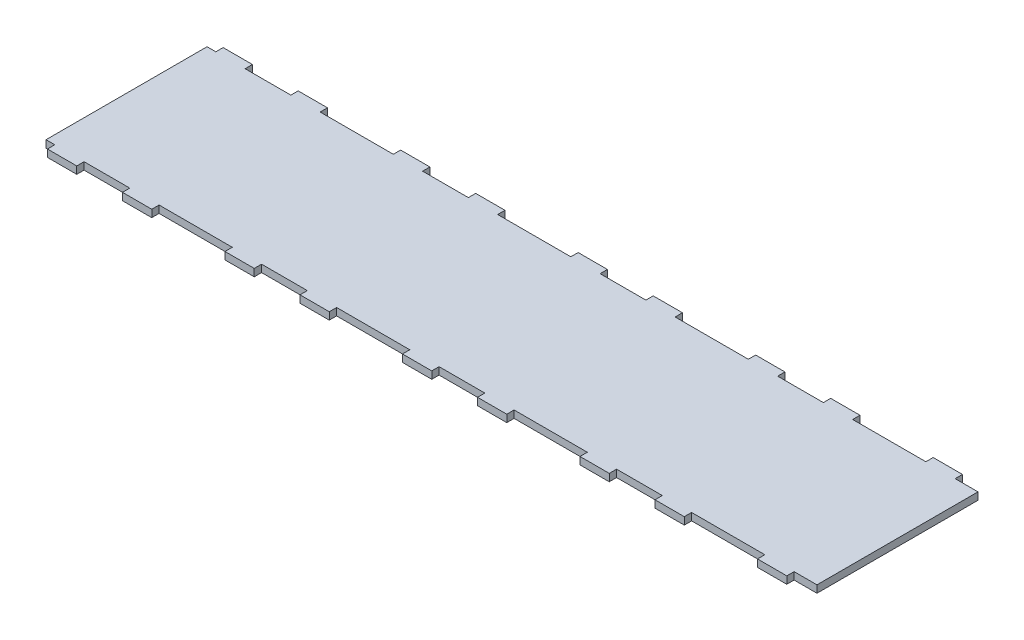
from build123d import *

# Parameters (mm, degrees)
SKETCH1_W                 = 721.63658441
SKETCH1_H                 = 152.4
BOSS_EXTRUDE1_DEPTH       = 6.35
SKETCH2_W                 = 39.679316882
SKETCH2_H                 = 6.35
SKETCH2_W_2               = 31.750000127
CUT_EXTRUDE1_DEPTH        = 7.35
LPATTERN1_COUNT           = 3
LPATTERN1_PITCH           = 153.979316882
LPATTERN1_COL_COUNT       = 3
LPATTERN1_COL_PITCH       = 153.979316882
MIRROR1_COPY_1_SKETCH_W   = 39.679316882
MIRROR1_COPY_1_SKETCH_H   = 6.35
MIRROR1_COPY_1_SKETCH_W_2 = 31.750000127
MIRROR1_COPY_1_DEPTH      = 7.35
MIRROR1_COPY_2_SKETCH_W   = 39.679316882
MIRROR1_COPY_2_SKETCH_H   = 6.35
MIRROR1_COPY_2_SKETCH_W_2 = 31.750000127
MIRROR1_COPY_2_DEPTH      = 7.35
MIRROR1_COPY_3_SKETCH_W   = 39.679316882
MIRROR1_COPY_3_SKETCH_H   = 6.35
MIRROR1_COPY_3_SKETCH_W_2 = 31.750000127
MIRROR1_COPY_3_DEPTH      = 7.35
MIRROR1_COPY_4_SKETCH_W   = 39.679316882
MIRROR1_COPY_4_SKETCH_H   = 6.35
MIRROR1_COPY_4_SKETCH_W_2 = 31.750000127
MIRROR1_COPY_4_DEPTH      = 7.35
CUT_EXTRUDE2_DEPTH        = 7.35


with BuildPart() as part:
    # Sketch1 → Boss-Extrude1 (new body)
    with BuildSketch(Plane(origin=(0, 0, 0), x_dir=(1, 0, 0), z_dir=(0, 1, 0))):
        Rectangle(SKETCH1_W, SKETCH1_H)
    extrude(amount=BOSS_EXTRUDE1_DEPTH)

    # Sketch2 → Cut-Extrude1 (cut, through all)
    with BuildSketch(Plane(origin=(0, 6.35, 0), x_dir=(1, 0, 0), z_dir=(0, 1, 0))):
        with Locations((0, -73.025)):
            Rectangle(SKETCH2_W, SKETCH2_H)
        with Locations((-61.114658505, -73.025)):
            Rectangle(SKETCH2_W_2, SKETCH2_H)
        with Locations((61.114658505, -73.025)):
            Rectangle(SKETCH2_W_2, SKETCH2_H)
    cut_extrude1 = extrude(amount=-CUT_EXTRUDE1_DEPTH, mode=Mode.SUBTRACT)

    # LPattern1: Cut-Extrude1 ×3
    with Locations(*[(i * LPATTERN1_PITCH, 0, 0) for i in range(1, LPATTERN1_COUNT)]):
        add(cut_extrude1, mode=Mode.SUBTRACT)

    # LPattern1 col: Cut-Extrude1 ×3
    with Locations(*[(-i * LPATTERN1_COL_PITCH, 0, 0) for i in range(1, LPATTERN1_COL_COUNT)]):
        add(cut_extrude1, mode=Mode.SUBTRACT)

    # Mirror1: Cut-Extrude1 across plane
    add(cut_extrude1.mirror(Plane.XY), mode=Mode.SUBTRACT)

    # Mirror1 copy 1 sketch → Mirror1 copy 1 (cut, through all)
    with BuildSketch(Plane(origin=(153.979316882, 6.35, 0), x_dir=(1, 0, 0), z_dir=(0, 1, 0))):
        with Locations((0, 73.025)):
            Rectangle(MIRROR1_COPY_1_SKETCH_W, MIRROR1_COPY_1_SKETCH_H)
        with Locations((-61.114658505, 73.025)):
            Rectangle(MIRROR1_COPY_1_SKETCH_W_2, MIRROR1_COPY_1_SKETCH_H)
        with Locations((61.114658505, 73.025)):
            Rectangle(MIRROR1_COPY_1_SKETCH_W_2, MIRROR1_COPY_1_SKETCH_H)
    extrude(amount=-MIRROR1_COPY_1_DEPTH, mode=Mode.SUBTRACT)

    # Mirror1 copy 2 sketch → Mirror1 copy 2 (cut, through all)
    with BuildSketch(Plane(origin=(307.958633764, 6.35, 0), x_dir=(1, 0, 0), z_dir=(0, 1, 0))):
        with Locations((0, 73.025)):
            Rectangle(MIRROR1_COPY_2_SKETCH_W, MIRROR1_COPY_2_SKETCH_H)
        with Locations((-61.114658505, 73.025)):
            Rectangle(MIRROR1_COPY_2_SKETCH_W_2, MIRROR1_COPY_2_SKETCH_H)
        with Locations((61.114658505, 73.025)):
            Rectangle(MIRROR1_COPY_2_SKETCH_W_2, MIRROR1_COPY_2_SKETCH_H)
    extrude(amount=-MIRROR1_COPY_2_DEPTH, mode=Mode.SUBTRACT)

    # Mirror1 copy 3 sketch → Mirror1 copy 3 (cut, through all)
    with BuildSketch(Plane(origin=(-153.979316882, 6.35, 0), x_dir=(1, 0, 0), z_dir=(0, 1, 0))):
        with Locations((0, 73.025)):
            Rectangle(MIRROR1_COPY_3_SKETCH_W, MIRROR1_COPY_3_SKETCH_H)
        with Locations((-61.114658505, 73.025)):
            Rectangle(MIRROR1_COPY_3_SKETCH_W_2, MIRROR1_COPY_3_SKETCH_H)
        with Locations((61.114658505, 73.025)):
            Rectangle(MIRROR1_COPY_3_SKETCH_W_2, MIRROR1_COPY_3_SKETCH_H)
    extrude(amount=-MIRROR1_COPY_3_DEPTH, mode=Mode.SUBTRACT)

    # Mirror1 copy 4 sketch → Mirror1 copy 4 (cut, through all)
    with BuildSketch(Plane(origin=(-307.958633764, 6.35, 0), x_dir=(1, 0, 0), z_dir=(0, 1, 0))):
        with Locations((0, 73.025)):
            Rectangle(MIRROR1_COPY_4_SKETCH_W, MIRROR1_COPY_4_SKETCH_H)
        with Locations((-61.114658505, 73.025)):
            Rectangle(MIRROR1_COPY_4_SKETCH_W_2, MIRROR1_COPY_4_SKETCH_H)
        with Locations((61.114658505, 73.025)):
            Rectangle(MIRROR1_COPY_4_SKETCH_W_2, MIRROR1_COPY_4_SKETCH_H)
    extrude(amount=-MIRROR1_COPY_4_DEPTH, mode=Mode.SUBTRACT)

    # Sketch3 → Cut-Extrude2 (cut, through all)
    with BuildSketch(Plane(origin=(0, 6.35, 0), x_dir=(1, 0, 0), z_dir=(0, 1, 0))):
        Polygon((307.958633764, 69.85), (307.958633764, -76.2), (360.818292205, -76.2), (360.818292205, 76.2), (307.958633764, 76.2), align=None)
    extrude(amount=-CUT_EXTRUDE2_DEPTH, mode=Mode.SUBTRACT)


solid = part.part
